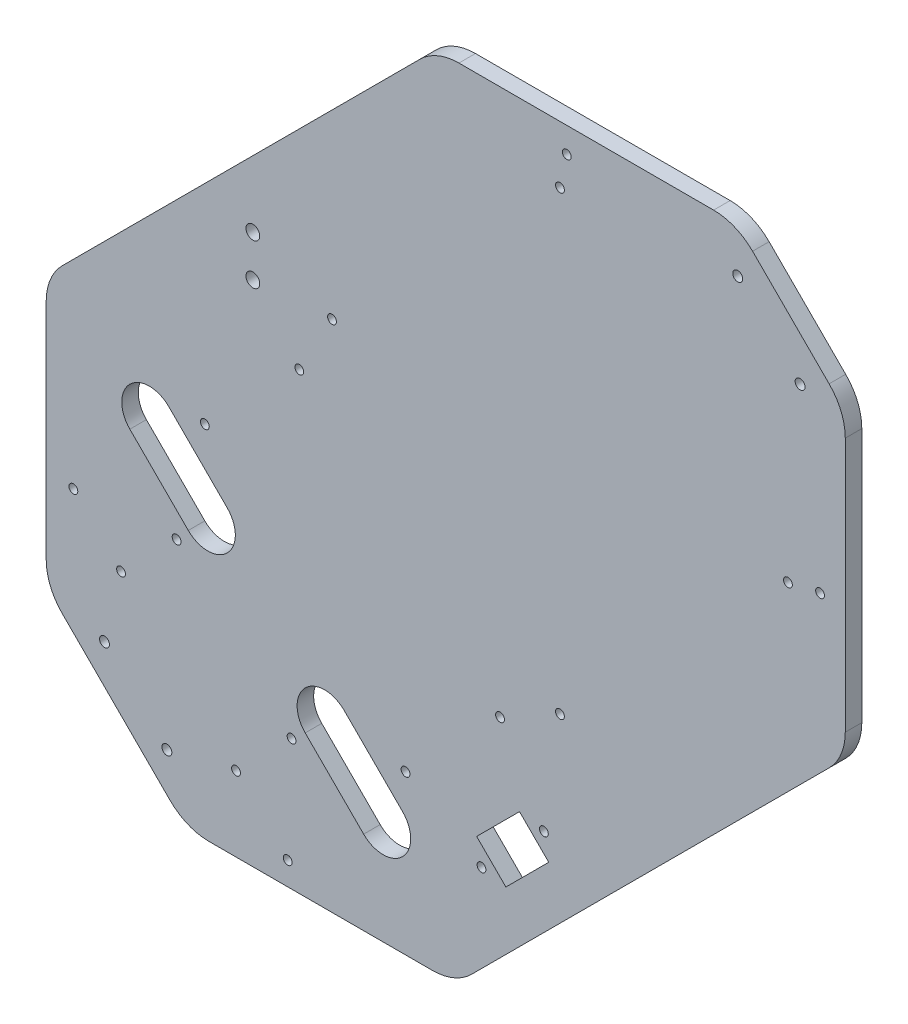
from build123d import *

# Parameters (mm, degrees)
SKETCH1_R           = 1.8
SKETCH1_R_2         = 1.6
SKETCH1_R_3         = 2.5
BOSS_EXTRUDE1_DEPTH = 6


with BuildPart() as part:
    # Sketch1 → Boss-Extrude1 (new body)
    with BuildSketch(Plane.XY):
        with BuildLine():
            Line((-157.361082537, 14.788780041), (-27.569235339, 144.58062724))
            ThreePointArc((-27.569235339, 144.58062724), (-21.080768362, 148.916082266), (-13.427099715, 150.438491616))
            Line((-13.427099715, 150.438491616), (78.999307156, 150.438491616))
            ThreePointArc((78.999307156, 150.438491616), (86.652975803, 148.916082266), (93.14144278, 144.58062724))
            Line((93.14144278, 144.58062724), (120.92318871, 116.798881309))
            ThreePointArc((120.92318871, 116.798881309), (125.258643737, 110.310414333), (126.781053087, 102.656745685))
            Line((126.781053087, 102.656745685), (126.781053087, 10.230338814))
            ThreePointArc((126.781053087, 10.230338814), (125.258643737, 2.576670167), (120.92318871, -3.91179681))
            Line((120.92318871, -3.91179681), (-8.868658488, -133.703644008))
            ThreePointArc((-8.868658488, -133.703644008), (-15.357125464, -138.039099034), (-23.010794112, -139.561508384))
            Line((-23.010794112, -139.561508384), (-104.123492484, -139.561508384))
            ThreePointArc((-104.123492484, -139.561508384), (-111.777161131, -138.039099034), (-118.265628108, -133.703644008))
            Line((-118.265628108, -133.703644008), (-157.361082537, -94.608189578))
            ThreePointArc((-157.361082537, -94.608189578), (-161.696537564, -88.119722602), (-163.218946913, -80.466053955))
            Line((-163.218946913, -80.466053955), (-163.218946913, 0.646644418))
            ThreePointArc((-163.218946913, 0.646644418), (-161.696537564, 8.300313065), (-157.361082537, 14.788780041))
        make_face()
        with Locations((-142.055996009, -95.771140482)):
            Circle(SKETCH1_R, mode=Mode.SUBTRACT)
        with Locations((-119.428579011, -118.39855748)):
            Circle(SKETCH1_R, mode=Mode.SUBTRACT)
        with Locations((87.753707876, 134.038563403)):
            Circle(SKETCH1_R, mode=Mode.SUBTRACT)
        with Locations((110.381124874, 111.411146405)):
            Circle(SKETCH1_R, mode=Mode.SUBTRACT)
        with Locations((23.240162175, 129.629094103)):
            Circle(SKETCH1_R_2, mode=Mode.SUBTRACT)
        with Locations((-59.491331224, 46.897600704)):
            Circle(SKETCH1_R_2, mode=Mode.SUBTRACT)
        with Locations((105.971655573, 46.897600704)):
            Circle(SKETCH1_R_2, mode=Mode.SUBTRACT)
        with Locations((23.240162175, -35.833892695)):
            Circle(SKETCH1_R_2, mode=Mode.SUBTRACT)
        with Locations((-153.35684456, -53.357593559)):
            Circle(SKETCH1_R_2, mode=Mode.SUBTRACT)
        with Locations((-75.57509863, -131.13933949)):
            Circle(SKETCH1_R_2, mode=Mode.SUBTRACT)
        with Locations((-105.639996778, -9.150559787)):
            Circle(SKETCH1_R_2, mode=Mode.SUBTRACT)
        with Locations((-32.807998316, -81.982558249)):
            Circle(SKETCH1_R_2, mode=Mode.SUBTRACT)
        with Locations((1.486680571, -47.687879362)):
            Circle(SKETCH1_R_2, mode=Mode.SUBTRACT)
        with Locations((-71.345317891, 25.144119101)):
            Circle(SKETCH1_R_2, mode=Mode.SUBTRACT)
        with Locations((-136.045588369, -70.66884975)):
            Circle(SKETCH1_R_2, mode=Mode.SUBTRACT)
        with Locations((-94.326288279, -112.38814984)):
            Circle(SKETCH1_R_2, mode=Mode.SUBTRACT)
        with Locations((-74.173745015, -92.235606576)):
            Circle(SKETCH1_R_2, mode=Mode.SUBTRACT)
        with Locations((-115.893045105, -50.516306486)):
            Circle(SKETCH1_R_2, mode=Mode.SUBTRACT)
        with Locations((-5.23083385, -98.246014216)):
            Circle(SKETCH1_R_2, mode=Mode.SUBTRACT)
        with Locations((17.396583148, -75.618597218)):
            Circle(SKETCH1_R_2, mode=Mode.SUBTRACT)
        with Locations((25.715035909, 141.296355992)):
            Circle(SKETCH1_R_2, mode=Mode.SUBTRACT)
        with Locations((117.638917463, 49.372474438)):
            Circle(SKETCH1_R_2, mode=Mode.SUBTRACT)
        with Locations((-88.218946913, 59.889285105)):
            Circle(SKETCH1_R_3, mode=Mode.SUBTRACT)
        with Locations((-88.218946913, 44.889285105)):
            Circle(SKETCH1_R_3, mode=Mode.SUBTRACT)
        with BuildLine():
            Line((-118.72147223, -10.211219959), (-97.508268795, -31.424423394))
            ThreePointArc((-97.508268795, -31.424423394), (-97.508268795, -45.566559018), (-111.650404418, -45.566559018))
            Line((-111.650404418, -45.566559018), (-132.863607854, -24.353355582))
            ThreePointArc((-132.863607854, -24.353355582), (-132.863607854, -10.211219959), (-118.72147223, -10.211219959))
        make_face(mode=Mode.SUBTRACT)
        with BuildLine():
            Line((-55.081861923, -73.850830265), (-33.868658488, -95.064033701))
            ThreePointArc((-33.868658488, -95.064033701), (-33.868658488, -109.206169325), (-48.010794112, -109.206169325))
            Line((-48.010794112, -109.206169325), (-69.223997547, -87.992965889))
            ThreePointArc((-69.223997547, -87.992965889), (-69.223997547, -73.850830265), (-55.081861923, -73.850830265))
        make_face(mode=Mode.SUBTRACT)
        Polygon((-6.998600803, -89.407179452), (3.608000915, -100.013781169), (19.164350101, -84.457431983), (8.557748383, -73.850830265), align=None, mode=Mode.SUBTRACT)
    extrude(amount=BOSS_EXTRUDE1_DEPTH)


solid = part.part
